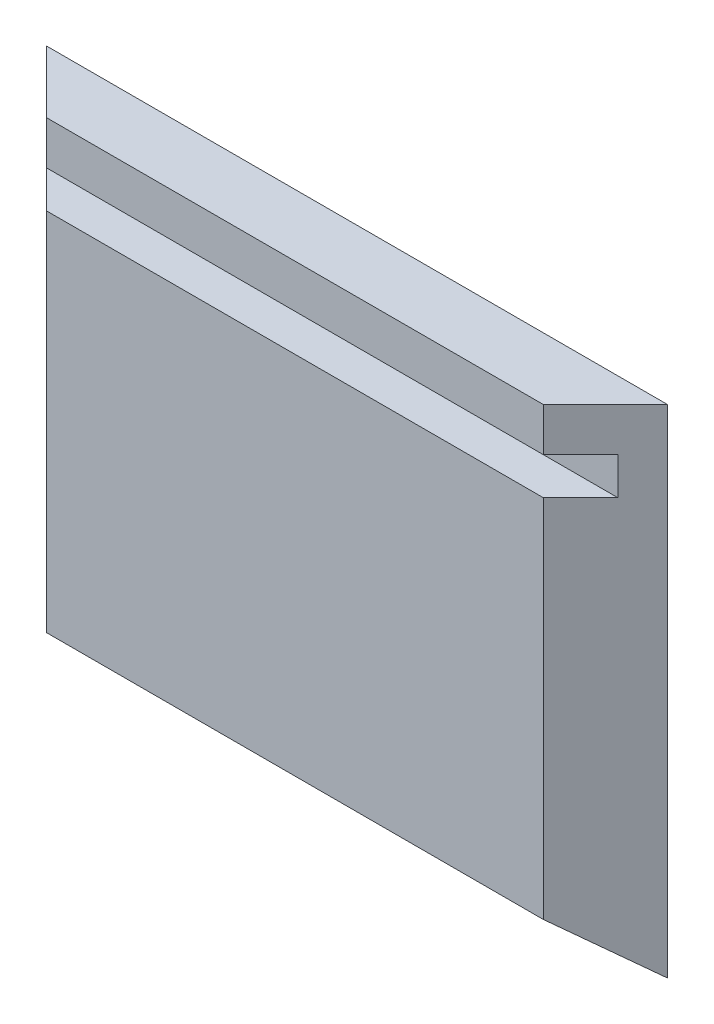
from build123d import *

# Parameters (mm, degrees)
SKETCH1_W               = 50
SKETCH1_H               = 40
BOSS_EXTRUDE1_DEPTH     = 5
CUT_EXTRUDE1_DEPTH      = 21
CUT_EXTRUDE1_DEPTH_BACK = 21
CUT_EXTRUDE2_DEPTH      = 26
CUT_EXTRUDE2_DEPTH_BACK = 26
SKETCH4_W               = 3
SKETCH4_H               = 3
CUT_EXTRUDE3_DEPTH      = 26
CUT_EXTRUDE3_DEPTH_BACK = 26


with BuildPart() as part:
    # Sketch1 → Boss-Extrude1 (new body)
    with BuildSketch(Plane.XY):
        Rectangle(SKETCH1_W, SKETCH1_H)
    extrude(amount=BOSS_EXTRUDE1_DEPTH)

    # Sketch2 → Cut-Extrude1 (cut, two sides)
    with BuildSketch(Plane(origin=(0, 0, 0), x_dir=(1, 0, 0), z_dir=(0, 1, 0))) as cut_extrude1_sk:
        Polygon((-25, 0), (-20, -5), (-25, -5), align=None)
        Polygon((25, 0), (20, -5), (25, -5), align=None)
    extrude(amount=CUT_EXTRUDE1_DEPTH, mode=Mode.SUBTRACT)
    extrude(cut_extrude1_sk.sketch, amount=-CUT_EXTRUDE1_DEPTH_BACK, mode=Mode.SUBTRACT)

    # Sketch3 → Cut-Extrude2 (cut, two sides)
    with BuildSketch(Plane(origin=(0, 0, 0), x_dir=(0, 0, -1), z_dir=(1, 0, 0))) as cut_extrude2_sk:
        Polygon((0, -20), (-5, -15.916820135), (-5, -20), align=None)
    extrude(amount=CUT_EXTRUDE2_DEPTH, mode=Mode.SUBTRACT)
    extrude(cut_extrude2_sk.sketch, amount=-CUT_EXTRUDE2_DEPTH_BACK, mode=Mode.SUBTRACT)

    # Sketch4 → Cut-Extrude3 (cut, two sides)
    with BuildSketch(Plane(origin=(0, 0, 0), x_dir=(0, 0, -1), z_dir=(1, 0, 0))) as cut_extrude3_sk:
        with Locations((-3.5, 15)):
            Rectangle(SKETCH4_W, SKETCH4_H)
    extrude(amount=CUT_EXTRUDE3_DEPTH, mode=Mode.SUBTRACT)
    extrude(cut_extrude3_sk.sketch, amount=-CUT_EXTRUDE3_DEPTH_BACK, mode=Mode.SUBTRACT)


solid = part.part
